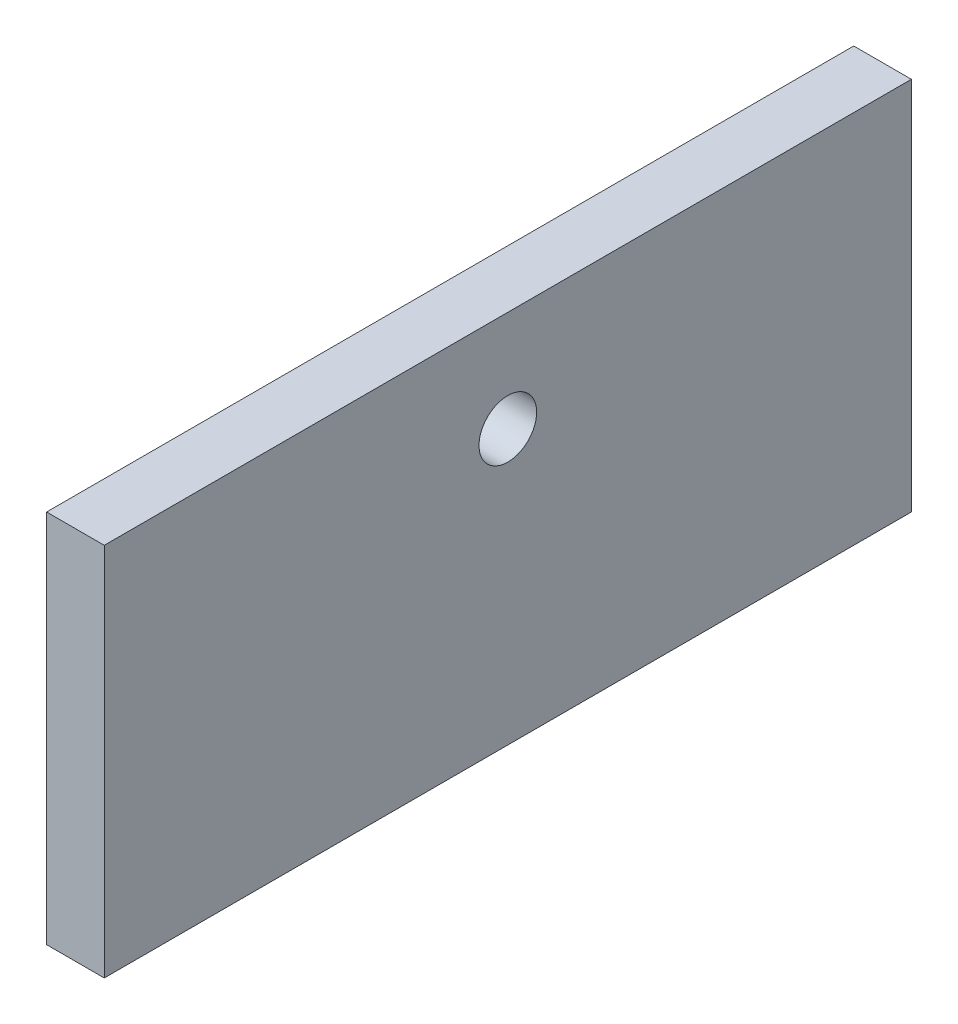
from build123d import *

# Parameters (mm, degrees)
CROQUIS6_W              = 140
CROQUIS6_H              = 65
CROQUIS6_R              = 5
SALIENTE_EXTRUIR4_DEPTH = 10


with BuildPart() as part:
    # Croquis6 → Saliente-Extruir4 (new body)
    with BuildSketch(Plane(origin=(0, 0, 0), x_dir=(0, 0, -1), z_dir=(1, 0, 0))):
        Rectangle(CROQUIS6_W, CROQUIS6_H)
        with Locations((0, 15)):
            Circle(CROQUIS6_R, mode=Mode.SUBTRACT)
    extrude(amount=SALIENTE_EXTRUIR4_DEPTH)


solid = part.part
